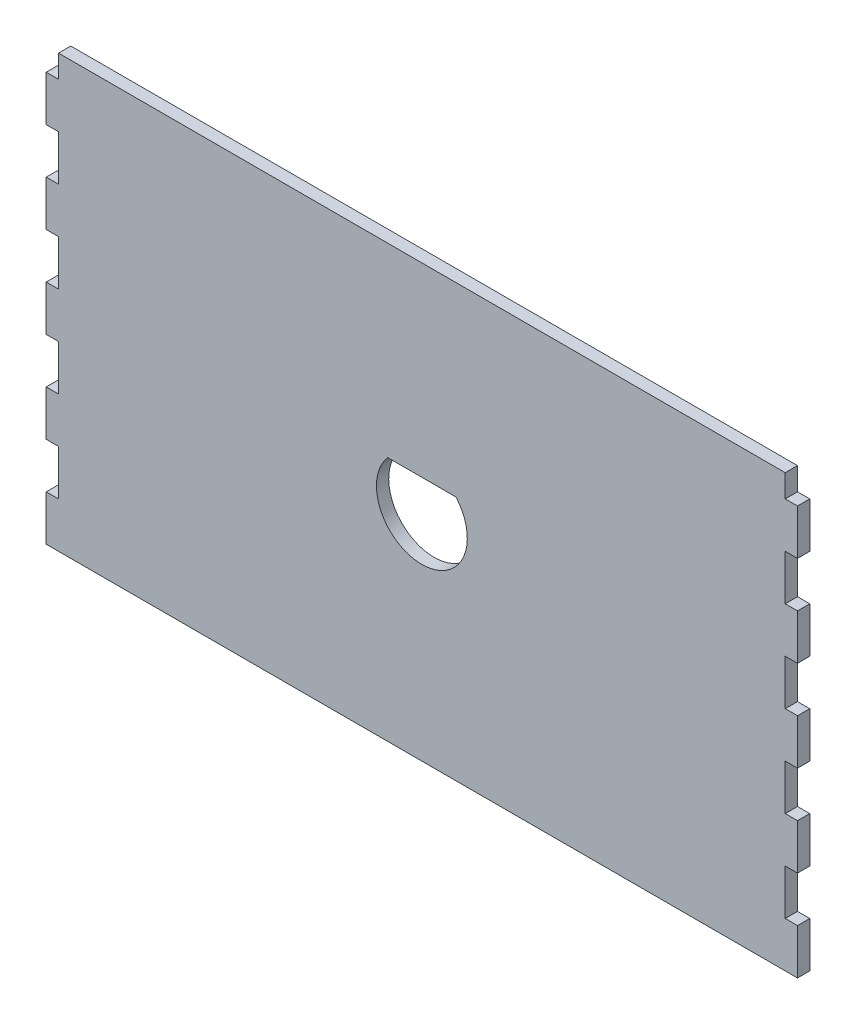
from build123d import *

# Parameters (mm, degrees)
BOSS_EXTRUDE1_DEPTH = 2.7


with BuildPart() as part:
    # Sketch1 → Boss-Extrude1 (new body)
    with BuildSketch(Plane.XY):
        Polygon((80, -17.5), (82.7, -17.5), (82.7, -27.5), (80, -27.5), (80, -37.5), (82.7, -37.5), (82.7, -47.5), (80, -47.5), (-80, -47.5), (-82.7, -47.5), (-82.7, -37.5), (-80, -37.5), (-80, -27.5), (-82.7, -27.5), (-82.7, -17.5), (-80, -17.5), (-80, -7.5), (-82.7, -7.5), (-82.7, 2.5), (-80, 2.5), (-80, 12.5), (-82.7, 12.5), (-82.7, 22.5), (-80, 22.5), (-80, 32.5), (-82.7, 32.5), (-82.7, 42.5), (-80, 42.5), (-80, 47.5), (80, 47.5), (80, 42.5), (82.7, 42.5), (82.7, 32.5), (80, 32.5), (80, 22.5), (82.7, 22.5), (82.7, 12.5), (80, 12.5), (80, 2.5), (82.7, 2.5), (82.7, -7.5), (80, -7.5), align=None)
        with BuildLine():
            ThreePointArc((-7.5, 6.614378278), (0, -10), (7.5, 6.614378278))
            Line((7.5, 6.614378278), (-7.5, 6.614378278))
        make_face(mode=Mode.SUBTRACT)
    extrude(amount=BOSS_EXTRUDE1_DEPTH)


solid = part.part
